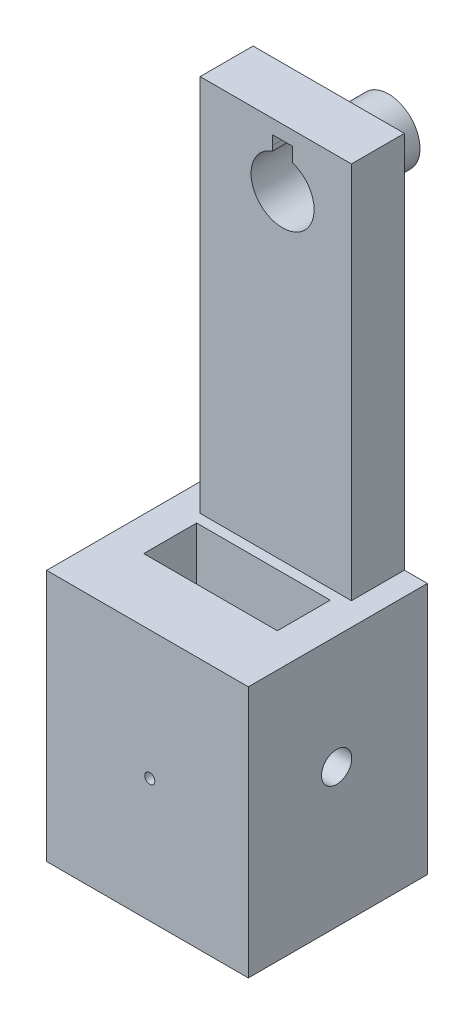
from build123d import *

# Parameters (mm, degrees)
BOSS_EXTRUDE1_DEPTH      = 20
BOSS_EXTRUDE1_DEPTH_BACK = 1
SKETCH8_W                = 8
SKETCH8_H                = 15
CUT_EXTRUDE23_DEPTH      = 22
SKETCH9_W                = 80
SKETCH9_H                = 100
BOSS_EXTRUDE2_DEPTH      = 50
SKETCH11_W               = 53
SKETCH11_H               = 21
CUT_EXTRUDE24_DEPTH      = 251
SKETCH12_R               = 6
CUT_EXTRUDE25_DEPTH      = 81
SKETCH13_R               = 2
CUT_EXTRUDE26_DEPTH      = 30
SKETCH16_R               = 12.5
BOSS_EXTRUDE4_DEPTH      = 20


with BuildPart() as part:
    # Sketch1 → Boss-Extrude1 (new body, two sides)
    with BuildSketch(Plane.XY) as boss_extrude1_sk:
        Polygon((-57.702904495, 32.624334465), (2.297095505, 32.624334465), (2.297095505, -117.375665535), (18.465683408, -117.375665535), (11.415868661, -117.375665535), (11.415868661, -217.375665535), (-68.584131339, -217.375665535), (-68.584131339, -117.375665535), (-57.702904495, -117.375665535), align=None)
        with BuildLine():
            Line((-21.012791673, 27.00780152), (-29.012791673, 27.00780152))
            Line((-29.012791673, 27.00780152), (-29.012791673, 21.350520803))
            ThreePointArc((-29.012791673, 21.350520803), (-25.012791673, -2.99219848), (-21.012791673, 21.350520803))
            Line((-21.012791673, 21.350520803), (-21.012791673, 27.00780152))
        make_face(mode=Mode.SUBTRACT)
    extrude(amount=BOSS_EXTRUDE1_DEPTH)
    extrude(boss_extrude1_sk.sketch, amount=-BOSS_EXTRUDE1_DEPTH_BACK)

    # Sketch8 → Cut-Extrude23 (cut, through all)
    with BuildSketch(Plane(origin=(0, 0, -1), x_dir=(-1, 0, 0), z_dir=(0, 0, -1))):
        with Locations((25.059223965, 15.809886429)):
            Rectangle(SKETCH8_W, SKETCH8_H)
    extrude(amount=-CUT_EXTRUDE23_DEPTH, mode=Mode.SUBTRACT)

    # Sketch9 → Boss-Extrude2 (add)
    with BuildSketch(Plane.XY.offset(20)):
        with Locations((-28.584131339, -167.375665535)):
            Rectangle(SKETCH9_W, SKETCH9_H)
    extrude(amount=BOSS_EXTRUDE2_DEPTH)

    # Sketch11 → Cut-Extrude24 (cut, through all)
    with BuildSketch(Plane.XZ.offset(217.375665535)):
        with Locations((-28.584131339, 34.5)):
            Rectangle(SKETCH11_W, SKETCH11_H)
    extrude(amount=-CUT_EXTRUDE24_DEPTH, mode=Mode.SUBTRACT)

    # Sketch12 → Cut-Extrude25 (cut, through all)
    with BuildSketch(Plane.ZY.offset(68.584131339)):
        with Locations((35, -162.375665535)):
            Circle(SKETCH12_R)
    extrude(amount=-CUT_EXTRUDE25_DEPTH, mode=Mode.SUBTRACT)

    # Sketch13 → Cut-Extrude26 (cut)
    with BuildSketch(Plane.XY.offset(70)):
        with Locations((-27.66721479, -168.370466124)):
            Circle(SKETCH13_R)
    extrude(amount=-CUT_EXTRUDE26_DEPTH, mode=Mode.SUBTRACT)


with BuildPart() as body_2:
    # Sketch16 → Boss-Extrude4 (new body)
    with BuildSketch(Plane(origin=(-25.012791673, 9.50780152, -2), x_dir=(-1, 0, 0), z_dir=(0, 0, -1))):
        Circle(SKETCH16_R)
    extrude(amount=BOSS_EXTRUDE4_DEPTH)


solid = Compound([part.part, body_2.part])
